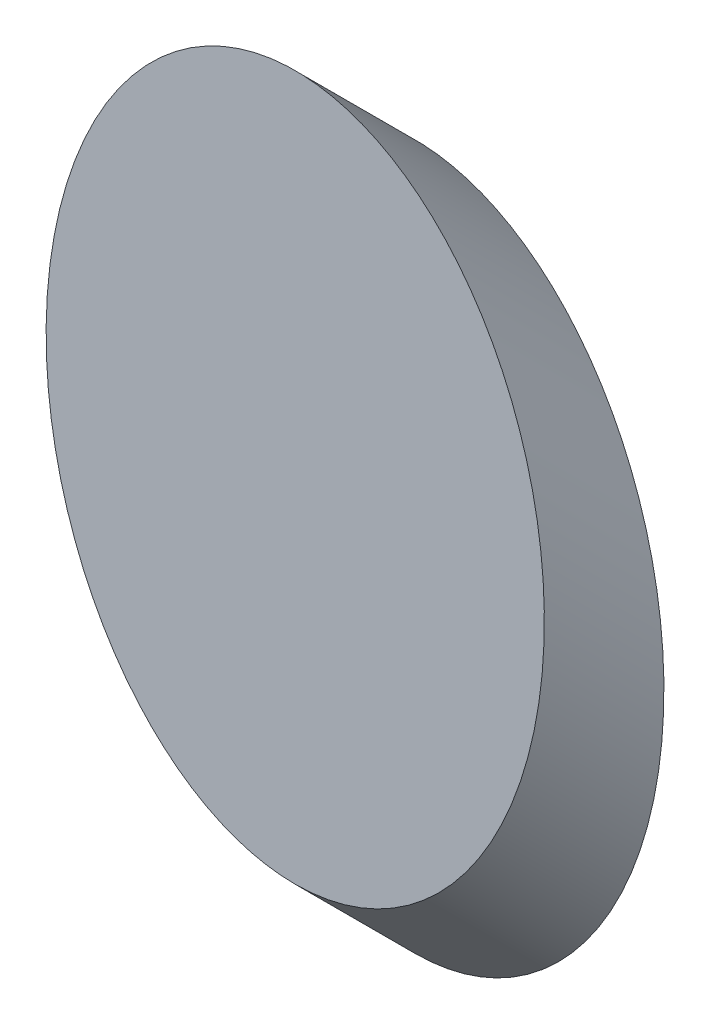
from build123d import *

# Parameters (mm, degrees)
SKETCH_1_RX     = 17.68
SKETCH_1_RY     = 12.5
EXTRUDE_2_DEPTH = 8.4853


with BuildPart() as part:
    # 草图1 → 凸台-拉伸2 (new body, along a direction that is not the sketch's normal)
    with BuildSketch(Plane.XY):
        with Locations(Location((54.392382982, 35.78887153), (0, 0, -90))):
            Ellipse(SKETCH_1_RX, SKETCH_1_RY)
    extrude(amount=-EXTRUDE_2_DEPTH, dir=(0, 0.707106781, 0.707106781))


solid = part.part
